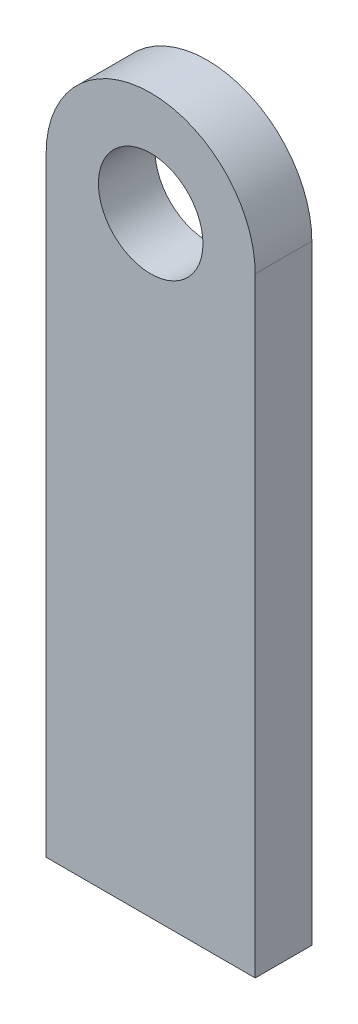
from build123d import *

# Parameters (mm, degrees)
SZKIC1_R                    = 6
DODANIE_WYCI_GNI_CIE1_DEPTH = 6.5


with BuildPart() as part:
    # Szkic1 → Dodanie-wyciągnięcie1 (new body)
    with BuildSketch(Plane.XY):
        with BuildLine():
            Line((12, 0), (12, -70))
            Line((12, -70), (-12, -70))
            Line((-12, -70), (-12, 0))
            ThreePointArc((-12, 0), (0, 12), (12, 0))
        make_face()
        Circle(SZKIC1_R, mode=Mode.SUBTRACT)
    extrude(amount=DODANIE_WYCI_GNI_CIE1_DEPTH)


solid = part.part
